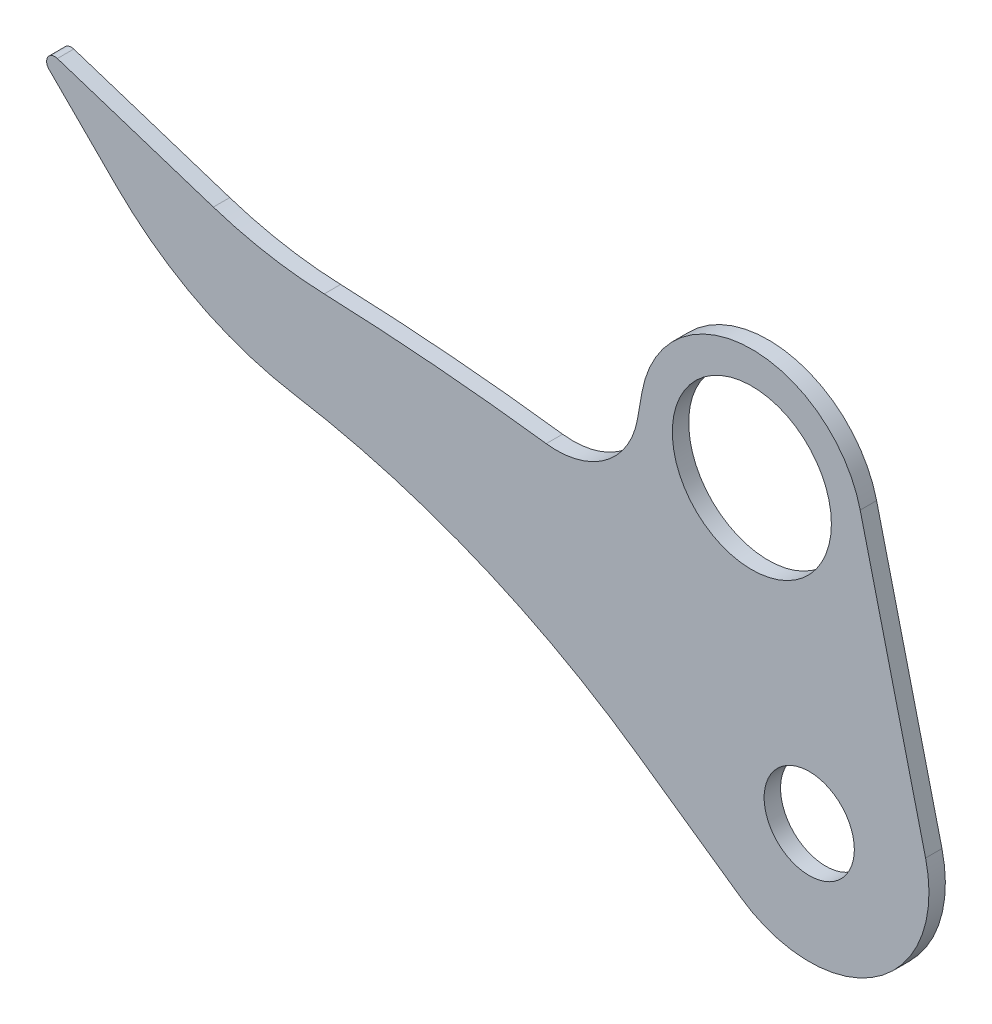
from build123d import *

# Parameters (mm, degrees)
SKETCH1_R          = 27.5
SKETCH1_R_2        = 48.5
BASE_EXTRUDE_DEPTH = 10


with BuildPart() as part:
    # Sketch1 → Base-Extrude (new body)
    with BuildSketch(Plane.XY):
        with BuildLine():
            Line((70.930675146, 17.258022001), (31.072409725, 181.075965699))
            ThreePointArc((31.072409725, 181.075965699), (-37.180312094, 232.965036888), (-101.966927205, 176.808076081))
            Line((-101.966927205, 176.808076081), (-104.698317648, 161.317591117))
            ThreePointArc((-104.698317648, 161.317591117), (-124.339394775, 129.702595413), (-160.381803445, 120.416872968))
            ThreePointArc((-160.381803445, 120.416872968), (-227.936557036, 127.643740719), (-295.749262378, 131.804190759))
            ThreePointArc((-295.749262378, 131.804190759), (-329.964920671, 135.496946415), (-363.349263399, 143.853583144))
            Line((-363.349263399, 143.853583144), (-458.454915028, 174.755282581))
            ThreePointArc((-458.454915028, 174.755282581), (-464.263200822, 172.612492824), (-463.535533906, 166.464466094))
            Line((-463.535533906, 166.464466094), (-422.516106966, 125.445039154))
            ThreePointArc((-422.516106966, 125.445039154), (-372.592477248, 89.023301508), (-313.933303895, 69.580741007))
            ThreePointArc((-313.933303895, 69.580741007), (-204.337272048, 38.490168586), (-104.328864588, -16.064687542))
            Line((-104.328864588, -16.064687542), (-41.871079854, -59.798099233))
            ThreePointArc((-41.871079854, -59.798099233), (41.176771055, -60.278300619), (70.930675146, 17.258022001))
        make_face()
        Circle(SKETCH1_R, mode=Mode.SUBTRACT)
        with Locations((-35, 165)):
            Circle(SKETCH1_R_2, mode=Mode.SUBTRACT)
    extrude(amount=BASE_EXTRUDE_DEPTH)


solid = part.part
